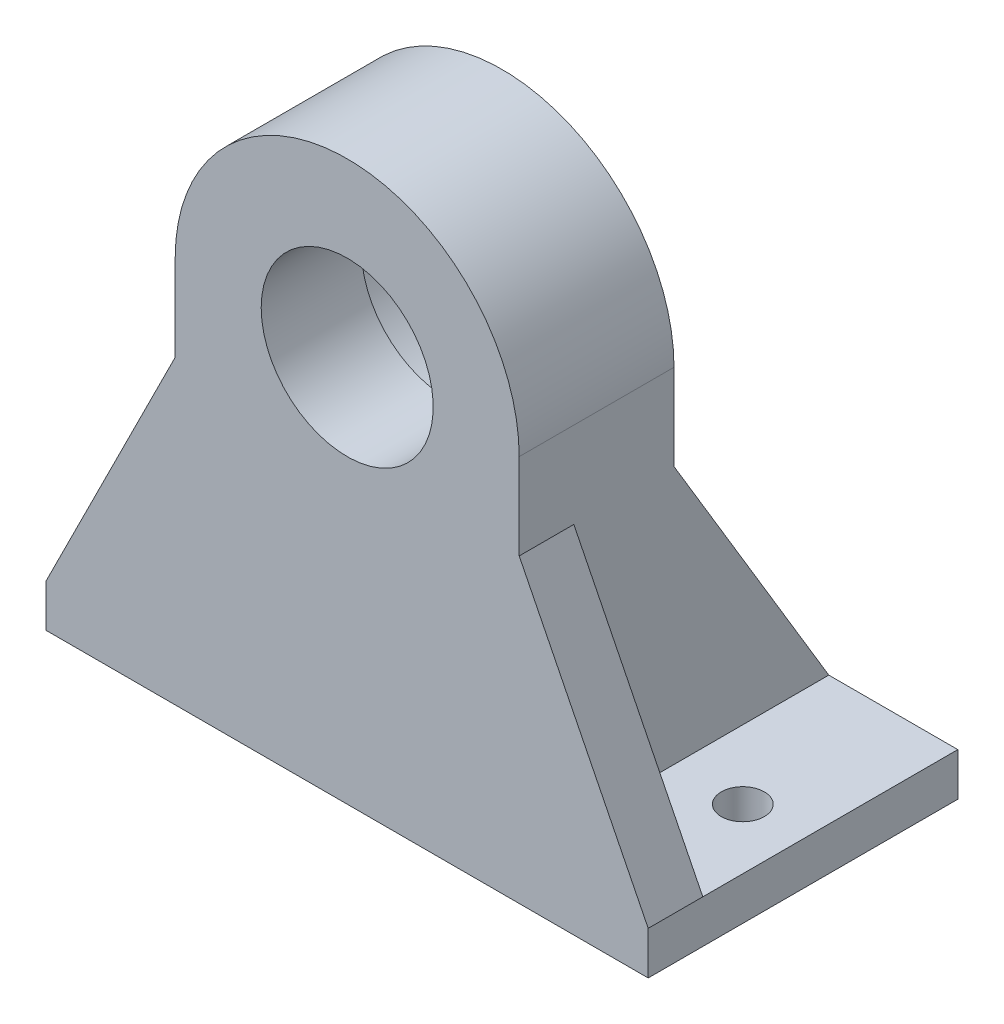
from build123d import *

# Parameters (mm, degrees)
BOSS_EXTRUDE1_DEPTH = 18
SKETCH6_W           = 70
SKETCH6_H           = 36
SKETCH6_R           = 2.5
BOSS_EXTRUDE2_DEPTH = 5
SKETCH7_R           = 10
CUT_EXTRUDE1_DEPTH  = 19
SKETCH8_R           = 14.2875
CUT_EXTRUDE2_DEPTH  = 6.35
CHAMFER1_SIZE       = 0.5
BOSS_EXTRUDE3_DEPTH = 6.35
BOSS_EXTRUDE4_DEPTH = 6.35


with BuildPart() as part:
    # Sketch3 → Boss-Extrude1 (new body)
    with BuildSketch(Plane.XY):
        with BuildLine():
            Line((-20, 0), (-20, -40))
            Line((-20, -40), (20, -40))
            Line((20, -40), (20, 0))
            ThreePointArc((20, 0), (0, 20), (-20, 0))
        make_face()
    extrude(amount=BOSS_EXTRUDE1_DEPTH)

    # Sketch6 → Boss-Extrude2 (add)
    with BuildSketch(Plane.XZ.offset(40)):
        Rectangle(SKETCH6_W, SKETCH6_H)
        with Locations((28, 0)):
            Circle(SKETCH6_R, mode=Mode.SUBTRACT)
        with Locations((-28, 0)):
            Circle(SKETCH6_R, mode=Mode.SUBTRACT)
    extrude(amount=BOSS_EXTRUDE2_DEPTH)

    # Sketch7 → Cut-Extrude1 (cut, through all)
    with BuildSketch(Plane(origin=(0, 0, 0), x_dir=(-1, 0, 0), z_dir=(0, 0, -1))):
        Circle(SKETCH7_R)
    extrude(amount=-CUT_EXTRUDE1_DEPTH, mode=Mode.SUBTRACT)

    # Sketch8 → Cut-Extrude2 (cut)
    with BuildSketch(Plane(origin=(0, 0, 0), x_dir=(-1, 0, 0), z_dir=(0, 0, -1))):
        Circle(SKETCH8_R)
    extrude(amount=-CUT_EXTRUDE2_DEPTH, mode=Mode.SUBTRACT)

    # Chamfer1
    chamfer1_edges = [part.edges().sort_by_distance(p)[0] for p in [
        (14.2875, 0, 0),
    ]]
    chamfer(chamfer1_edges, length=CHAMFER1_SIZE)

    # Sketch9 → Boss-Extrude3 (add)
    with BuildSketch(Plane(origin=(20, 0, 0), x_dir=(0, 0, -1), z_dir=(1, 0, 0))):
        Polygon((18, -40), (0, -10), (0, -40), align=None)
    boss_extrude3 = extrude(amount=-BOSS_EXTRUDE3_DEPTH)

    # Mirror1: Boss-Extrude3 across plane
    add(boss_extrude3.mirror(Plane(origin=(0, 0, 0), x_dir=(0, 0, 1), z_dir=(1, 0, 0))))

    # Sketch10 → Boss-Extrude4 (add)
    with BuildSketch(Plane.XY.offset(18)):
        Polygon((-20, -10), (-35, -40), (-20, -40), align=None)
        Polygon((20, -10), (20, -40), (35, -40), align=None)
    extrude(amount=-BOSS_EXTRUDE4_DEPTH)


solid = part.part
